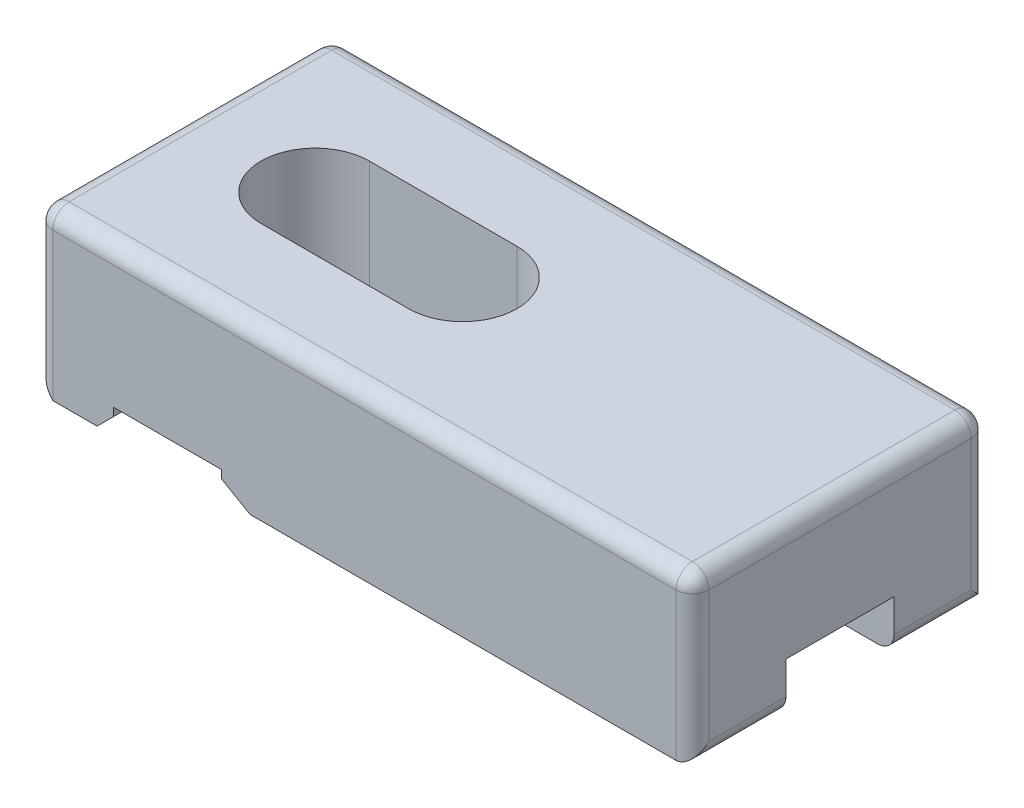
from build123d import *

# Parameters (mm, degrees)
SKETCH_1_W             = 40
SKETCH_1_H             = 18
EXTRUDE_1_DEPTH        = 10
CUT_EXTRUDE_1_DEPTH    = 3
CUT_EXTRUDE_2_DEPTH    = 1.5
CHAMFER_1_SIZE         = 1
CHAMFER_2_SIZE         = 1
CHAMFER_2_SIZE2        = 1.732050808
CHAMFER_2_PART_2_SIZE  = 1
CHAMFER_2_PART_2_SIZE2 = 1.732050808
FILLET_1_R             = 1


with BuildPart() as part:
    # 草图1 → 凸台-拉伸1 (new body)
    with BuildSketch(Plane(origin=(0, 0, 0), x_dir=(1, 0, 0), z_dir=(0, 1, 0))):
        with Locations((20, 9)):
            Rectangle(SKETCH_1_W, SKETCH_1_H)
        with BuildLine():
            Line((17, 5.7), (8, 5.7))
            ThreePointArc((8, 5.7), (4.7, 9), (8, 12.3))
            Line((8, 12.3), (17, 12.3))
            ThreePointArc((17, 12.3), (20.3, 9), (17, 5.7))
        make_face(mode=Mode.SUBTRACT)
    extrude(amount=EXTRUDE_1_DEPTH)

    # 草图2 → 切除-拉伸1 (cut)
    with BuildSketch(Plane.XZ):
        with BuildLine():
            Line((40, -5.7), (40, -12.3))
            Line((40, -12.3), (8, -12.3))
            ThreePointArc((8, -12.3), (4.7, -9), (8, -5.7))
            Line((8, -5.7), (40, -5.7))
        make_face()
    extrude(amount=-CUT_EXTRUDE_1_DEPTH, mode=Mode.SUBTRACT)

    # 草图3 → 切除-拉伸2 (cut)
    with BuildSketch(Plane.XZ):
        Polygon((0, -5.7), (4.7, -5.7), (4.7, 0), (11.3, 0), (11.3, -18), (4.7, -18), (4.7, -12.3), (0, -12.3), align=None)
    extrude(amount=-CUT_EXTRUDE_2_DEPTH, mode=Mode.SUBTRACT)

    # 倒角1
    chamfer_1_edges = [part.edges().sort_by_distance(p)[0] for p in [
        (0, 0, -15.15),
        (0, 0, -2.85),
        (4.7, 0, -2.85),
        (4.7, 0, -15.15),
    ]]
    chamfer(chamfer_1_edges, length=CHAMFER_1_SIZE)

    # 倒角2
    chamfer_2_edges = [part.edges().sort_by_distance(p)[0] for p in [
        (11.3, 0, -2.85),
    ]]
    chamfer_2_side = [part.faces().sort_by_distance(p)[0] for p in [
        (11.3, 0.75, -2.85),
    ]]
    chamfer(chamfer_2_edges, length=CHAMFER_2_SIZE, length2=CHAMFER_2_SIZE2, reference=chamfer_2_side[0])

    # 倒角2 part 2
    chamfer_2_part_2_edges = [part.edges().sort_by_distance(p)[0] for p in [
        (11.3, 0, -15.15),
    ]]
    chamfer_2_part_2_side = [part.faces().sort_by_distance(p)[0] for p in [
        (11.3, 0.75, -15.15),
    ]]
    chamfer(chamfer_2_part_2_edges, length=CHAMFER_2_PART_2_SIZE, length2=CHAMFER_2_PART_2_SIZE2, reference=chamfer_2_part_2_side[0])

    # 圆角1
    fillet_1_edges = [part.edges().sort_by_distance(p)[0] for p in [
        (20, 10, -18),
        (40, 10, -9),
        (20, 10, 0),
        (0, 10, -9),
        (40, 5, 0),
        (40, 5, -18),
        (0, 5.5, -18),
        (0, 5.5, 0),
        (40, 0, -15.15),
        (40, 0, -2.85),
    ]]
    fillet(fillet_1_edges, radius=FILLET_1_R)


solid = part.part
